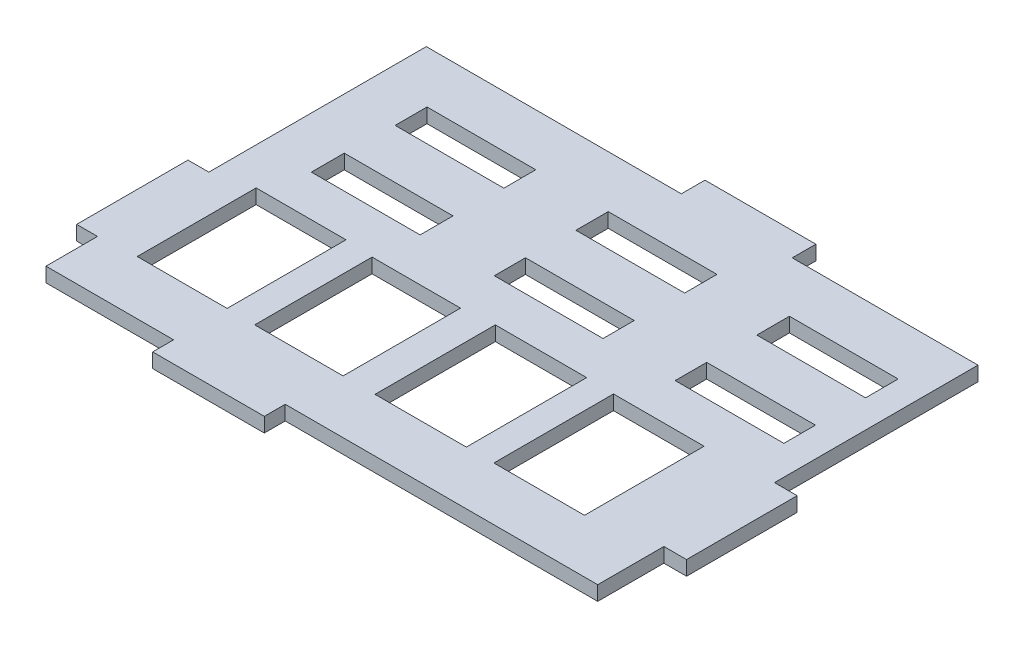
from build123d import *

# Parameters (mm, degrees)
SKETCH1_W           = 19.05
SKETCH1_H           = 5.7658
SKETCH1_H_2         = 5.5245
SKETCH1_H_3         = 5.461
SKETCH1_W_2         = 15.748
SKETCH1_H_4         = 20.828
SKETCH1_W_3         = 15.494
SKETCH1_H_5         = 20.574
SKETCH1_W_4         = 16.002
SKETCH1_H_6         = 21.082
SKETCH1_W_5         = 15.875
SKETCH1_H_7         = 20.955
SKETCH1_H_8         = 5.588
SKETCH1_H_9         = 5.715
SKETCH1_H_10        = 5.6642
BOSS_EXTRUDE1_DEPTH = 2.54


with BuildPart() as part:
    # Sketch1 → Boss-Extrude1 (new body)
    with BuildSketch(Plane(origin=(0, 0, 0), x_dir=(1, 0, 0), z_dir=(0, 1, 0))):
        Polygon((56.951560312, 84.213691439), (56.951560312, 75.188096428), (79.306647339, 75.188096428), (79.306647339, 71.525938437), (98.864647339, 71.525938437), (98.864647339, 75.188096428), (153.617936559, 75.188096428), (153.617936559, 86.784930064), (157.585274382, 86.784930064), (157.585274382, 106.165130064), (153.617936559, 106.165130064), (153.617936559, 141.820891439), (121.062786422, 141.820891439), (121.062786422, 145.967343453), (101.631786422, 145.967343453), (101.631786422, 141.820891439), (56.951560312, 141.820891439), (56.951560312, 134.591745655), (56.953910325, 134.591745655), (56.953910325, 116.049745655), (56.951560312, 116.049745655), (56.951560312, 103.720891439), (53.296575292, 103.720891439), (53.296575292, 84.213691439), align=None)
        with Locations((75.457604332, 115.587849021)):
            Rectangle(SKETCH1_W, SKETCH1_H, mode=Mode.SUBTRACT)
        with Locations((138.957604332, 115.708499021)):
            Rectangle(SKETCH1_W, SKETCH1_H_2, mode=Mode.SUBTRACT)
        with Locations((107.207604332, 115.740249021)):
            Rectangle(SKETCH1_W, SKETCH1_H_3, mode=Mode.SUBTRACT)
        with Locations((71.358442331, 95.058042907)):
            Rectangle(SKETCH1_W_2, SKETCH1_H_4, mode=Mode.SUBTRACT)
        with Locations((91.888312798, 94.844972613)):
            Rectangle(SKETCH1_W_3, SKETCH1_H_5, mode=Mode.SUBTRACT)
        with Locations((113.229534733, 95.098972613)):
            Rectangle(SKETCH1_W_4, SKETCH1_H_6, mode=Mode.SUBTRACT)
        with Locations((133.995045787, 95.035472613)):
            Rectangle(SKETCH1_W_5, SKETCH1_H_7, mode=Mode.SUBTRACT)
        with Locations((75.70300706, 129.926754737)):
            Rectangle(SKETCH1_W, SKETCH1_H_8, mode=Mode.SUBTRACT)
        with Locations((139.20300706, 129.863254737)):
            Rectangle(SKETCH1_W, SKETCH1_H_9, mode=Mode.SUBTRACT)
        with Locations((107.45300706, 129.888654737)):
            Rectangle(SKETCH1_W, SKETCH1_H_10, mode=Mode.SUBTRACT)
    extrude(amount=BOSS_EXTRUDE1_DEPTH)


solid = part.part
